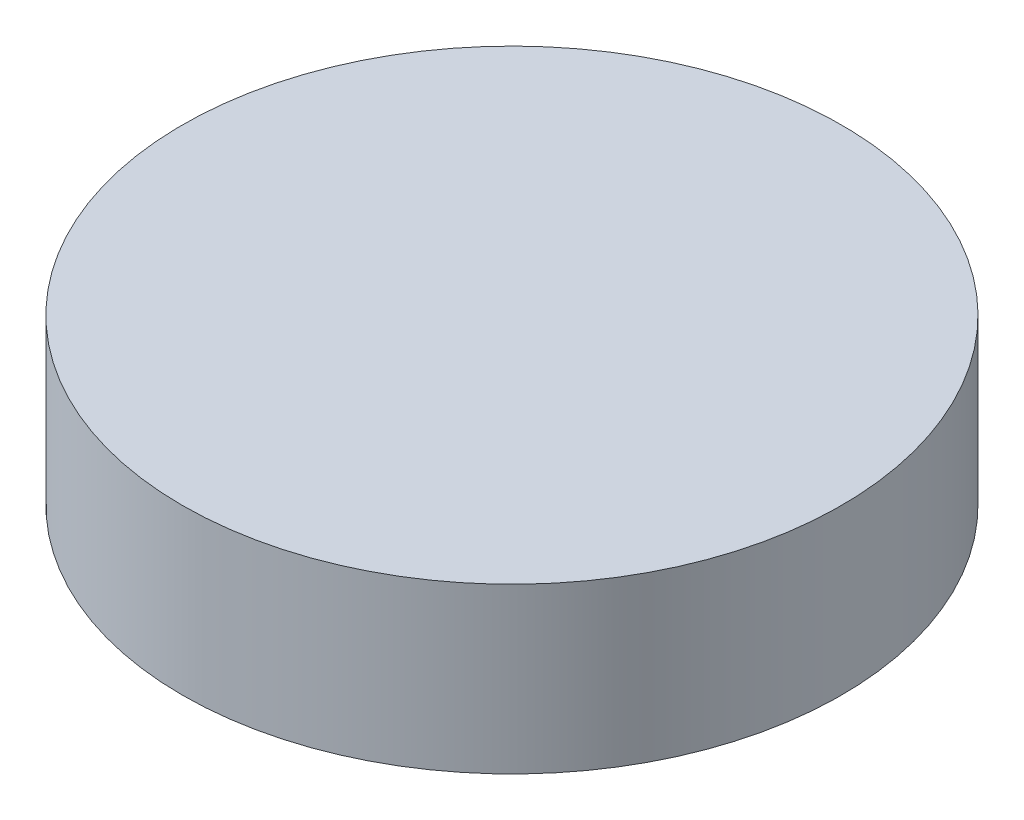
from build123d import *

# Parameters (mm, degrees)
SKETCH1_R           = 12.735895867
BOSS_EXTRUDE1_DEPTH = 6.35


with BuildPart() as part:
    # Sketch1 → Boss-Extrude1 (new body)
    with BuildSketch(Plane(origin=(0, 0, 0), x_dir=(1, 0, 0), z_dir=(0, 1, 0))):
        with Locations((-28.440043746, -17.507879122)):
            Circle(SKETCH1_R)
    extrude(amount=BOSS_EXTRUDE1_DEPTH)


solid = part.part
